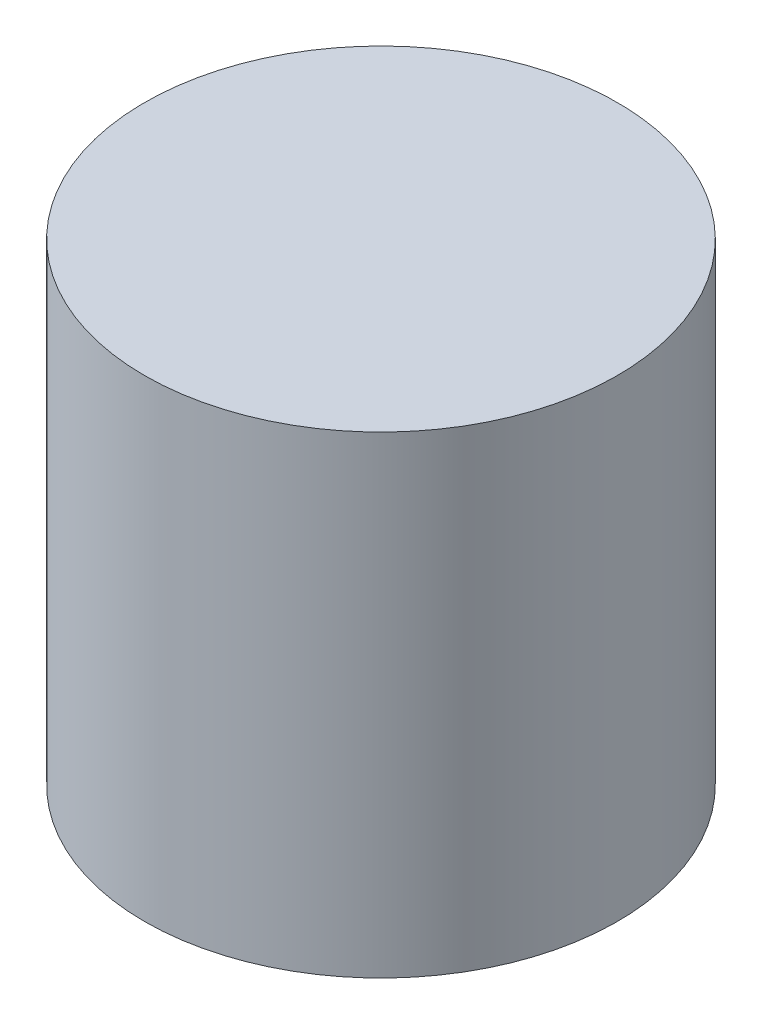
from build123d import *

# Parameters (mm, degrees)
SKETCH1_R           = 1
BOSS_EXTRUDE1_DEPTH = 2


with BuildPart() as part:
    # Sketch1 → Boss-Extrude1 (new body)
    with BuildSketch(Plane(origin=(0, 0, 0), x_dir=(1, 0, 0), z_dir=(0, 1, 0))):
        Circle(SKETCH1_R)
    extrude(amount=BOSS_EXTRUDE1_DEPTH)


solid = part.part
